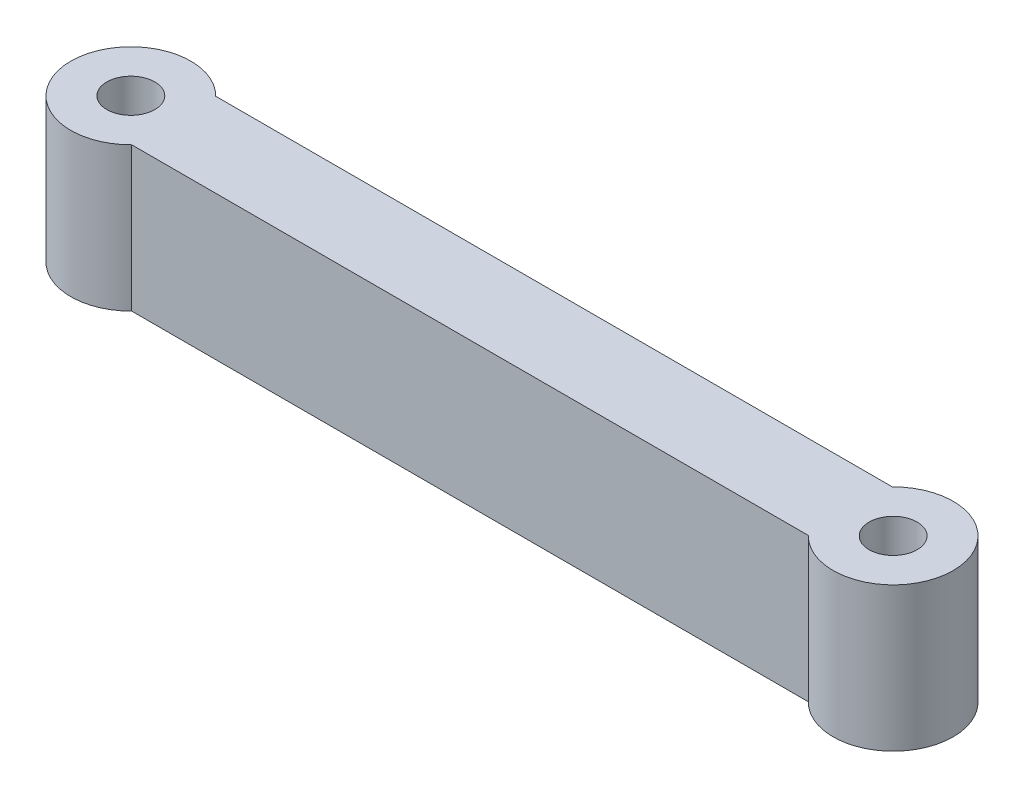
from build123d import *

# Parameters (mm, degrees)
CROQUIS1_W              = 56
CROQUIS1_H              = 5
SALIENTE_EXTRUIR1_DEPTH = 12
CROQUIS2_R              = 4
SALIENTE_EXTRUIR2_DEPTH = 12
CROQUIS3_W              = 61.198456306
CROQUIS3_H              = 5.5
SALIENTE_EXTRUIR3_DEPTH = 12
CROQUIS4_R              = 2
CORTAR_EXTRUIR1_DEPTH   = 12
CROQUIS5_R              = 5
SALIENTE_EXTRUIR4_DEPTH = 12
CROQUIS6_W              = 56.358571572
CROQUIS6_H              = 7
SALIENTE_EXTRUIR5_DEPTH = 12
CROQUIS7_R              = 2
CORTAR_EXTRUIR2_DEPTH   = 12


with BuildPart() as part:
    # Croquis1 → Saliente-Extruir1 (new body)
    with BuildSketch(Plane(origin=(0, 0, 0), x_dir=(1, 0, 0), z_dir=(0, 1, 0))):
        Rectangle(CROQUIS1_W, CROQUIS1_H)
    extrude(amount=SALIENTE_EXTRUIR1_DEPTH)

    # Croquis2 → Saliente-Extruir2 (add)
    with BuildSketch(Plane(origin=(0, 12, 0), x_dir=(1, 0, 0), z_dir=(0, 1, 0))):
        with Locations((31.75, 0)):
            Circle(CROQUIS2_R)
        with Locations((-31.75, 0)):
            Circle(CROQUIS2_R)
    extrude(amount=-SALIENTE_EXTRUIR2_DEPTH)

    # Croquis3 → Saliente-Extruir3 (add)
    with BuildSketch(Plane(origin=(0, 12, 0), x_dir=(1, 0, 0), z_dir=(0, 1, 0))):
        Rectangle(CROQUIS3_W, CROQUIS3_H)
    extrude(amount=-SALIENTE_EXTRUIR3_DEPTH)

    # Croquis4 → Cortar-Extruir1 (cut)
    with BuildSketch(Plane(origin=(0, 12, 0), x_dir=(1, 0, 0), z_dir=(0, 1, 0))):
        with Locations((-31.75, 0)):
            Circle(CROQUIS4_R)
        with Locations((31.75, 0)):
            Circle(CROQUIS4_R)
    extrude(amount=-CORTAR_EXTRUIR1_DEPTH, mode=Mode.SUBTRACT)

    # Croquis5 → Saliente-Extruir4 (add)
    with BuildSketch(Plane(origin=(0, 12, 0), x_dir=(1, 0, 0), z_dir=(0, 1, 0))):
        with Locations((-31.75, 0)):
            Circle(CROQUIS5_R)
        with Locations((31.75, 0)):
            Circle(CROQUIS5_R)
    extrude(amount=-SALIENTE_EXTRUIR4_DEPTH)

    # Croquis6 → Saliente-Extruir5 (add)
    with BuildSketch(Plane(origin=(0, 12, 0), x_dir=(1, 0, 0), z_dir=(0, 1, 0))):
        Rectangle(CROQUIS6_W, CROQUIS6_H)
    extrude(amount=-SALIENTE_EXTRUIR5_DEPTH)

    # Croquis7 → Cortar-Extruir2 (cut)
    with BuildSketch(Plane(origin=(0, 12, 0), x_dir=(1, 0, 0), z_dir=(0, 1, 0))):
        with Locations((31.75, 0)):
            Circle(CROQUIS7_R)
        with Locations((-31.75, 0)):
            Circle(CROQUIS7_R)
    extrude(amount=-CORTAR_EXTRUIR2_DEPTH, mode=Mode.SUBTRACT)


solid = part.part
